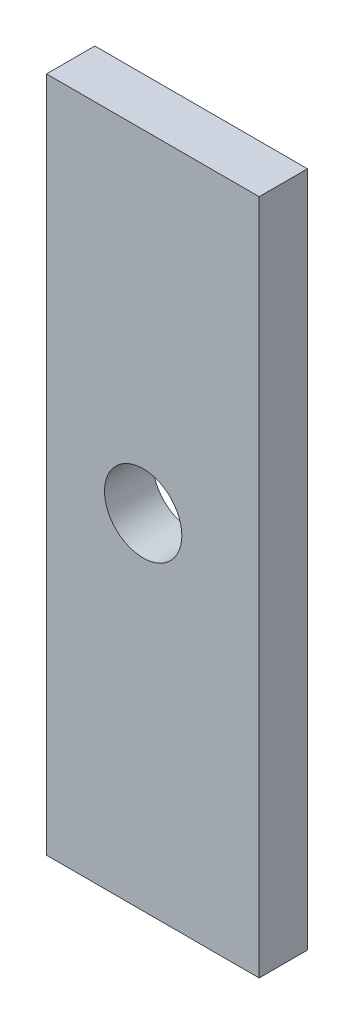
from build123d import *

# Parameters (mm, degrees)
SKETCH1_W           = 150
SKETCH1_H           = 70
BOSS_EXTRUDE1_DEPTH = 2.5
SKETCH2_R           = 4
CUT_EXTRUDE1_DEPTH  = 6
SKETCH3_W           = 120
SKETCH3_H           = 70
CUT_EXTRUDE2_DEPTH  = 6
SKETCH4_W           = 8
SKETCH4_H           = 70
CUT_EXTRUDE3_DEPTH  = 6


with BuildPart() as part:
    # Sketch1 → Boss-Extrude1 (new body, symmetric)
    with BuildSketch(Plane.XY):
        Rectangle(SKETCH1_W, SKETCH1_H)
    extrude(amount=BOSS_EXTRUDE1_DEPTH, both=True)

    # Sketch2 → Cut-Extrude1 (cut, through all)
    with BuildSketch(Plane.XY.offset(2.5)):
        with Locations((63, 0.628549325)):
            Circle(SKETCH2_R)
        with Locations((29.001496193, 0.309583996)):
            Circle(SKETCH2_R)
        with Locations((-42.995335398, -0.365871995)):
            Circle(SKETCH2_R)
        with Locations((-3.99705162, 0)):
            Circle(SKETCH2_R)
    extrude(amount=-CUT_EXTRUDE1_DEPTH, mode=Mode.SUBTRACT)

    # Sketch3 → Cut-Extrude2 (cut, through all)
    with BuildSketch(Plane(origin=(0, 0, -2.5), x_dir=(-1, 0, 0), z_dir=(0, 0, -1))):
        with Locations((15, 0)):
            Rectangle(SKETCH3_W, SKETCH3_H)
    extrude(amount=-CUT_EXTRUDE2_DEPTH, mode=Mode.SUBTRACT)

    # Sketch4 → Cut-Extrude3 (cut, through all)
    with BuildSketch(Plane(origin=(0, 0, -2.5), x_dir=(-1, 0, 0), z_dir=(0, 0, -1))):
        with Locations((-49, 0)):
            Rectangle(SKETCH4_W, SKETCH4_H)
    extrude(amount=-CUT_EXTRUDE3_DEPTH, mode=Mode.SUBTRACT)


solid = part.part
